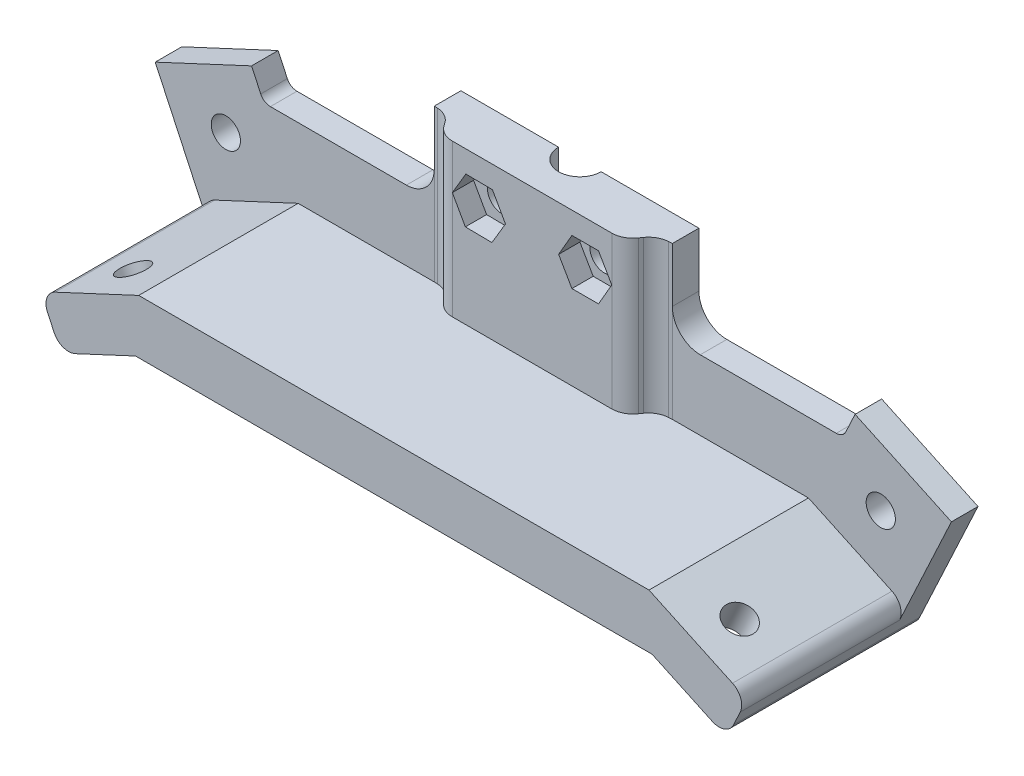
from build123d import *

# Parameters (mm, degrees)
SKETCH1_R           = 2.75
BOSS_EXTRUDE1_DEPTH = 5
BOSS_EXTRUDE2_DEPTH = 28.65
BOSS_EXTRUDE3_DEPTH = 30
SKETCH5_R           = 4
CUT_EXTRUDE1_DEPTH  = 54.54
CUT_EXTRUDE2_DEPTH  = 4
SKETCH11_R          = 6
CUT_EXTRUDE5_DEPTH  = 3.08
SKETCH13_R          = 2.75
CUT_EXTRUDE7_DEPTH  = 10
SKETCH14_R          = 2.75
CUT_EXTRUDE8_DEPTH  = 10
SKETCH12_R          = 6
CUT_EXTRUDE9_DEPTH  = 5


with BuildPart() as part:
    # Sketch1 → Boss-Extrude1 (new body)
    with BuildSketch(Plane.XY):
        with BuildLine():
            Line((0, 0), (44.78, 0))
            Line((44.78, 0), (44.78, -10.25))
            ThreePointArc((44.78, -10.25), (46.317689399, -13.962310601), (50.03, -15.5))
            Line((50.03, -15.5), (75.615859478, -15.5))
            ThreePointArc((75.615859478, -15.5), (76.690458695, -15.186782892), (77.428475052, -14.345236523))
            Line((77.428475052, -14.345236523), (79.157544549, -10.637235023))
            Line((79.157544549, -10.637235023), (97.28370029, -19.089600257))
            Line((97.28370029, -19.089600257), (86.295625484, -42.65360272))
            ThreePointArc((86.295625484, -42.65360272), (84.602762553, -44.204825797), (82.308847338, -44.104671296))
            Line((82.308847338, -44.104671296), (70.98, -38.821943024))
            Line((70.98, -38.821943024), (-26.2, -38.821943024))
            Line((-26.2, -38.821943024), (-37.528847338, -44.104671296))
            ThreePointArc((-37.528847338, -44.104671296), (-39.822762553, -44.204825797), (-41.515625484, -42.65360272))
            Line((-41.515625484, -42.65360272), (-52.50370029, -19.089600257))
            Line((-52.50370029, -19.089600257), (-34.377544549, -10.637235023))
            Line((-34.377544549, -10.637235023), (-32.648475052, -14.345236523))
            ThreePointArc((-32.648475052, -14.345236523), (-31.910458695, -15.186782892), (-30.835859478, -15.5))
            Line((-30.835859478, -15.5), (-5.25, -15.5))
            ThreePointArc((-5.25, -15.5), (-1.537689399, -13.962310601), (0, -10.25))
            Line((0, -10.25), (0, 0))
        make_face()
        with Locations((12.75, -8.45)):
            Circle(SKETCH1_R, mode=Mode.SUBTRACT)
        with Locations((32.03, -8.45)):
            Circle(SKETCH1_R, mode=Mode.SUBTRACT)
        with Locations((-39.214439802, -23.92649551)):
            Circle(SKETCH1_R, mode=Mode.SUBTRACT)
        with Locations((83.994439802, -23.92649551)):
            Circle(SKETCH1_R, mode=Mode.SUBTRACT)
    extrude(amount=BOSS_EXTRUDE1_DEPTH)

    # Sketch2 → Boss-Extrude2 (add)
    with BuildSketch(Plane(origin=(0, 0, 0), x_dir=(1, 0, 0), z_dir=(0, 1, 0))):
        with BuildLine():
            Line((0, -5), (0.654143487, -5.034282208))
            ThreePointArc((0.654143487, -5.034282208), (2.384038143, -5.530321518), (3.72140784, -6.734494601))
            Line((3.72140784, -6.734494601), (4.113391823, -7.294305745))
            ThreePointArc((4.113391823, -7.294305745), (5.543005547, -8.548043333), (7.39, -9))
            Line((7.39, -9), (37.39, -9))
            ThreePointArc((37.39, -9), (39.236994453, -8.548043333), (40.666608177, -7.294305745))
            Line((40.666608177, -7.294305745), (41.05859216, -6.734494601))
            ThreePointArc((41.05859216, -6.734494601), (42.395961857, -5.530321518), (44.125856513, -5.034282208))
            Line((44.125856513, -5.034282208), (44.78, -5))
            Line((44.78, -5), (0, -5))
        make_face()
    extrude(amount=-BOSS_EXTRUDE2_DEPTH)

    # Sketch4 → Boss-Extrude3 (add)
    with BuildSketch(Plane.XY.offset(5)):
        with BuildLine():
            Line((-25.61, -28.65), (22.39, -28.65))
            Line((22.39, -28.65), (70.39, -28.65))
            Line((70.39, -28.65), (86.099549898, -35.975483423))
            ThreePointArc((86.099549898, -35.975483423), (87.650772975, -37.668346355), (87.550618473, -39.96226157))
            Line((87.550618473, -39.96226157), (86.295625484, -42.65360272))
            ThreePointArc((86.295625484, -42.65360272), (84.602762553, -44.204825797), (82.308847338, -44.104671296))
            Line((82.308847338, -44.104671296), (70.98, -38.821943024))
            Line((70.98, -38.821943024), (-26.2, -38.821943024))
            Line((-26.2, -38.821943024), (-37.528847338, -44.104671296))
            ThreePointArc((-37.528847338, -44.104671296), (-39.822762553, -44.204825797), (-41.515625484, -42.65360272))
            Line((-41.515625484, -42.65360272), (-42.770618473, -39.96226157))
            ThreePointArc((-42.770618473, -39.96226157), (-42.870772975, -37.668346355), (-41.319549898, -35.975483423))
            Line((-41.319549898, -35.975483423), (-25.61, -28.65))
        make_face()
    extrude(amount=BOSS_EXTRUDE3_DEPTH)

    # Sketch5 → Cut-Extrude1 (cut)
    with BuildSketch(Plane(origin=(0, 0, 0), x_dir=(1, 0, 0), z_dir=(0, 1, 0))):
        with Locations((22.39, 0)):
            Circle(SKETCH5_R)
    extrude(amount=-CUT_EXTRUDE1_DEPTH, mode=Mode.SUBTRACT)

    # Sketch8 → Cut-Extrude2 (cut)
    with BuildSketch(Plane.XY.offset(9)):
        Polygon((29.89, -12.785779767), (34.89, -12.785779767), (37.39, -8.455652749), (34.89, -4.12552573), (29.89, -4.12552573), (27.39, -8.455652749), align=None)
        Polygon((14.938954238, -4.153789472), (9.938954238, -4.097261987), (7.39, -8.399125263), (9.841045762, -12.757516025), (14.841045762, -12.81404351), (17.39, -8.512180234), align=None)
    extrude(amount=-CUT_EXTRUDE2_DEPTH, mode=Mode.SUBTRACT)

    # Sketch11 → Cut-Extrude5 (cut)
    with BuildSketch(Plane(origin=(-2.19219913, -4.701186206, 0), x_dir=(0.906307787, -0.422618262, 0), z_dir=(-0.422618262, -0.906307787, 0))):
        with Locations((86.736588802, 27)):
            Circle(SKETCH11_R)
    extrude(amount=-CUT_EXTRUDE5_DEPTH, mode=Mode.SUBTRACT)

    # Sketch13 → Cut-Extrude7 (cut)
    with BuildSketch(Plane(origin=(6.39948199, -13.723733415, 0), x_dir=(0.906307787, 0.422618262, 0), z_dir=(-0.422618262, 0.906307787, 0))):
        with Locations((-45.318555625, -27)):
            Circle(SKETCH13_R)
    extrude(amount=-CUT_EXTRUDE7_DEPTH, mode=Mode.SUBTRACT)

    # Sketch14 → Cut-Extrude8 (cut)
    with BuildSketch(Plane(origin=(1.598503429, 3.428001667, 0), x_dir=(0.906307787, -0.422618262, 0), z_dir=(0.422618262, 0.906307787, 0))):
        with Locations((85.903018328, -27)):
            Circle(SKETCH14_R)
    extrude(amount=-CUT_EXTRUDE8_DEPTH, mode=Mode.SUBTRACT)

    # Sketch12 → Cut-Extrude9 (cut)
    with BuildSketch(Plane(origin=(10.190184549, -21.852921287, 0), x_dir=(0.906307787, 0.422618262, 0), z_dir=(0.422618262, -0.906307787, 0))):
        with Locations((-46.152126099, 27)):
            Circle(SKETCH12_R)
    extrude(amount=-CUT_EXTRUDE9_DEPTH, mode=Mode.SUBTRACT)


solid = part.part
